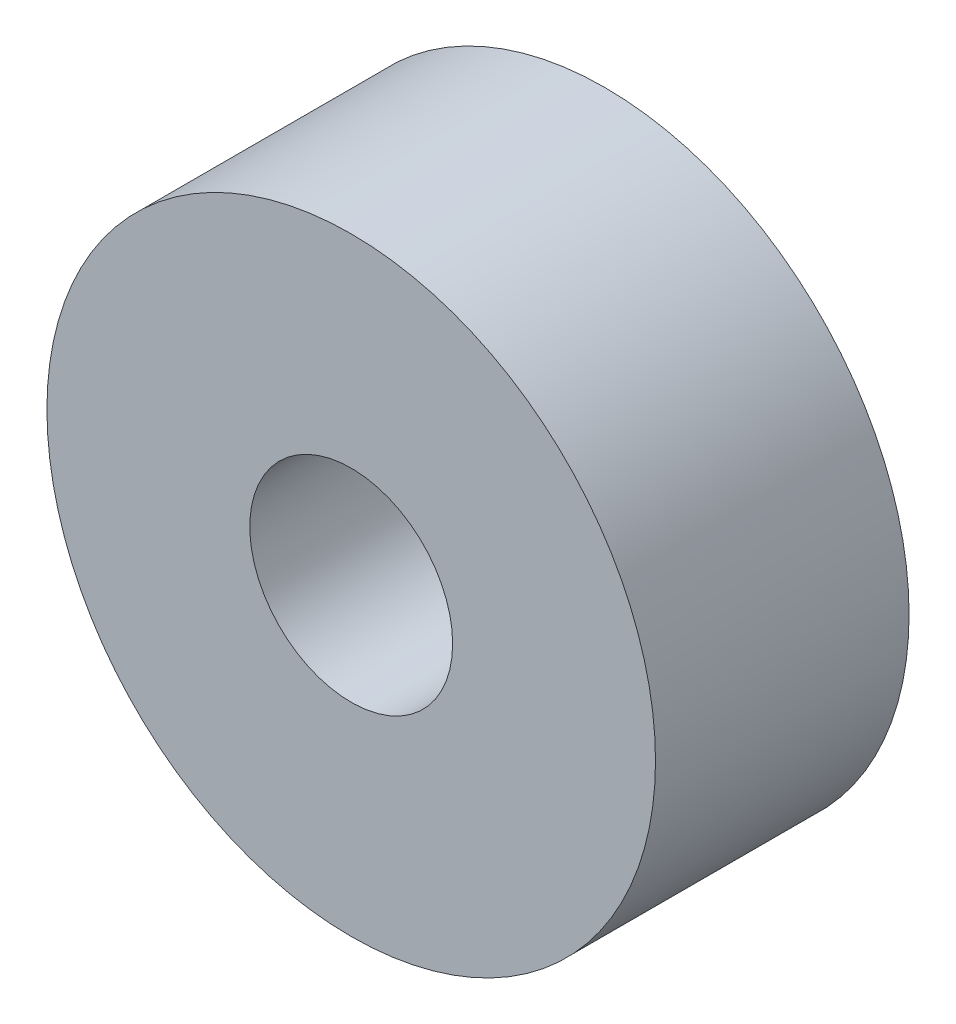
from build123d import *

# Parameters (mm, degrees)
SKETCH1_R      = 4.7625
EXTRUDE1_DEPTH = 3.96875
SKETCH2_R      = 1.5875
EXTRUDE2_DEPTH = 4.96875


with BuildPart() as part:
    # Sketch1 → Extrude1 (new body)
    with BuildSketch(Plane.XY):
        Circle(SKETCH1_R)
    extrude(amount=EXTRUDE1_DEPTH)

    # Sketch2 → Extrude2 (cut, through all)
    with BuildSketch(Plane.XY.offset(3.96875)):
        Circle(SKETCH2_R)
    extrude(amount=-EXTRUDE2_DEPTH, mode=Mode.SUBTRACT)


solid = part.part
